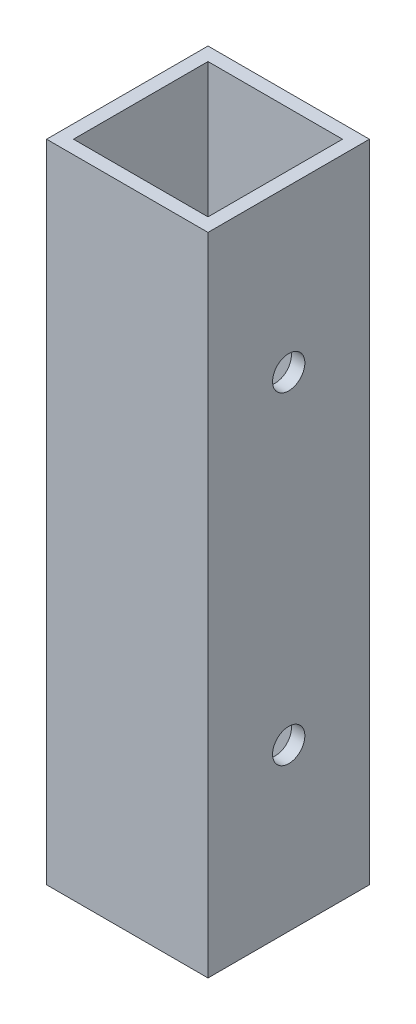
from build123d import *

# Parameters (mm, degrees)
SKETCH1_W           = 38.1
SKETCH1_H           = 38.1
SKETCH1_W_2         = 31.75
SKETCH1_H_2         = 31.75
BOSS_EXTRUDE1_DEPTH = 152.4
SKETCH2_R           = 3.81
CUT_EXTRUDE1_DEPTH  = 152.4


with BuildPart() as part:
    # Sketch1 → Boss-Extrude1 (new body)
    with BuildSketch(Plane(origin=(0, 0, 0), x_dir=(1, 0, 0), z_dir=(0, 1, 0))):
        Rectangle(SKETCH1_W, SKETCH1_H)
        Rectangle(SKETCH1_W_2, SKETCH1_H_2, mode=Mode.SUBTRACT)
    extrude(amount=BOSS_EXTRUDE1_DEPTH)

    # Sketch2 → Cut-Extrude1 (cut)
    with BuildSketch(Plane.ZY.offset(19.05)):
        with Locations((0, 114.3)):
            Circle(SKETCH2_R)
        with Locations((0, 38.1)):
            Circle(SKETCH2_R)
    extrude(amount=-CUT_EXTRUDE1_DEPTH, mode=Mode.SUBTRACT)


solid = part.part
